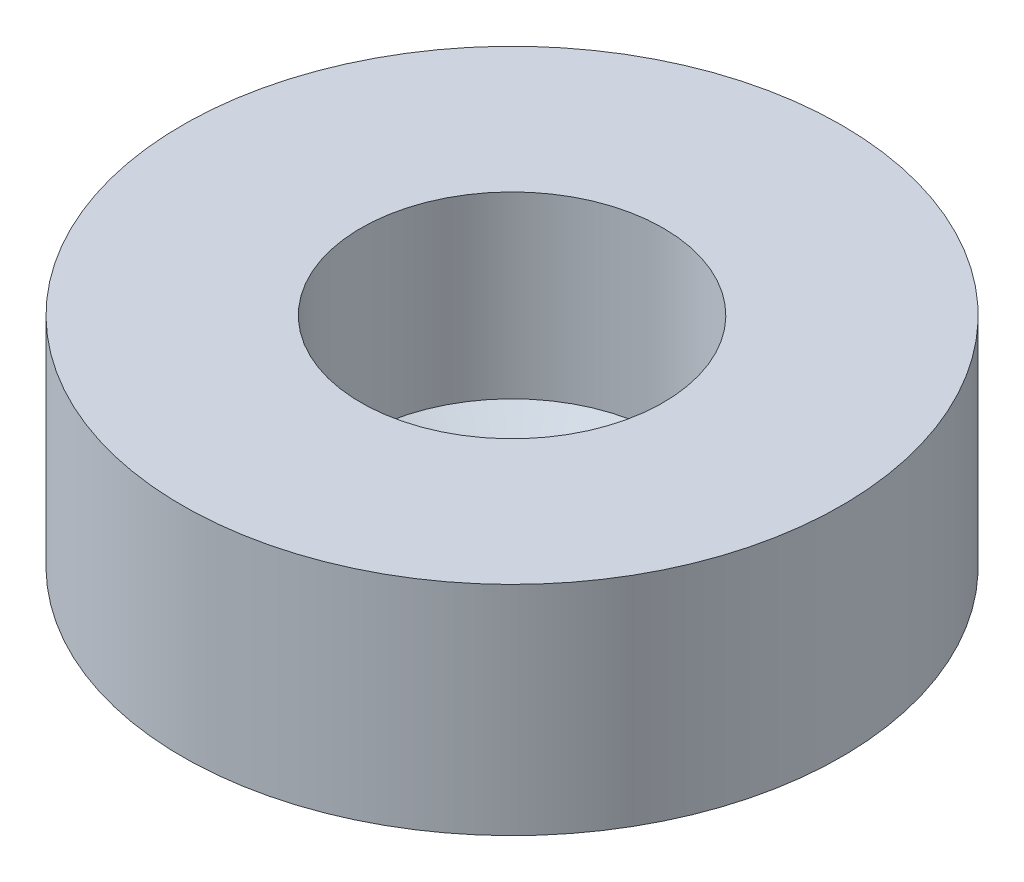
from build123d import *


with BuildPart() as part:
    # Sketch1 → Revolve1 (revolve)
    with BuildSketch(Plane.XY):
        Polygon((-1.73181913, 0), (-3.000000096, 0.762), (-3.000000096, 4.318), (-6.5405, 4.318), (-6.5405, 0), align=None)
    revolve(axis=Axis((0, 0, 0), (0, 1, 0)))


solid = part.part
